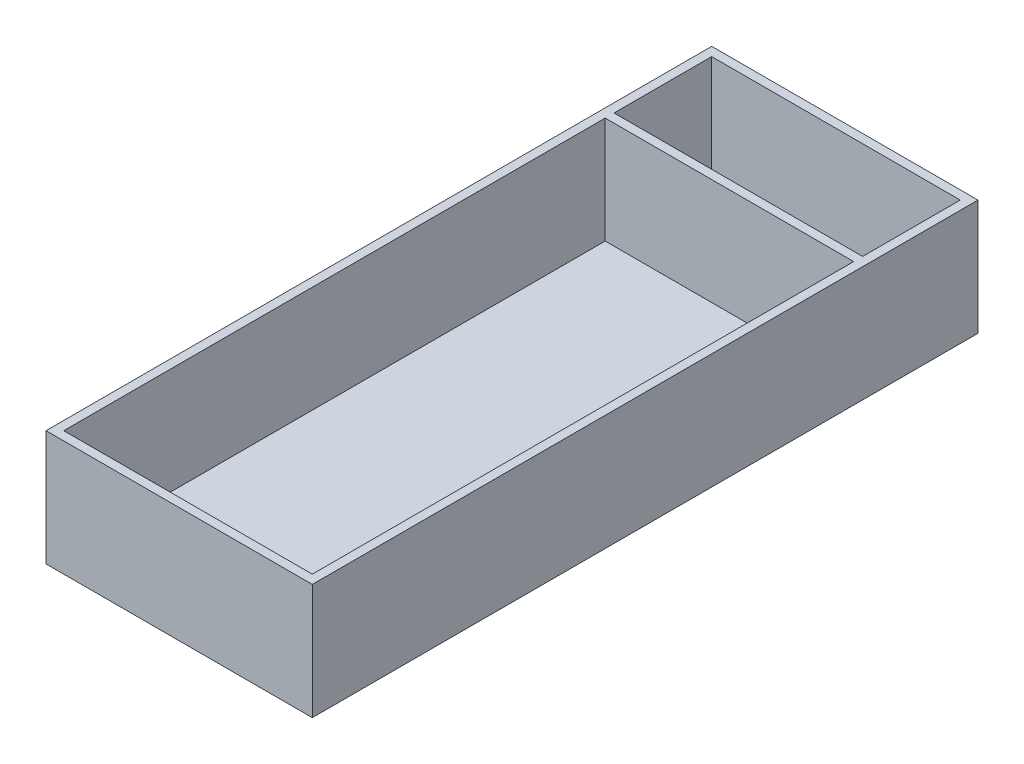
from build123d import *

# Parameters (mm, degrees)
SKETCH1_W           = 76.2
SKETCH1_H           = 190.5
SKETCH1_W_2         = 71.12
SKETCH1_H_2         = 185.42
EXTRUDE_THIN1_DEPTH = 30.48
SKETCH2_W           = 76.2
SKETCH2_H           = 190.5
BOSS_EXTRUDE1_DEPTH = 2.54
SKETCH4_W           = 71.12
SKETCH4_H           = 2.54
BOSS_EXTRUDE2_DEPTH = 30.48


with BuildPart() as part:
    # Sketch1 → Extrude-Thin1 (new body)
    with BuildSketch(Plane(origin=(0, 0, 0), x_dir=(1, 0, 0), z_dir=(0, 1, 0))):
        Rectangle(SKETCH1_W, SKETCH1_H)
        Rectangle(SKETCH1_W_2, SKETCH1_H_2, mode=Mode.SUBTRACT)
    extrude(amount=EXTRUDE_THIN1_DEPTH)

    # Sketch2 → Boss-Extrude1 (add)
    with BuildSketch(Plane.XZ):
        Rectangle(SKETCH2_W, SKETCH2_H)
    extrude(amount=BOSS_EXTRUDE1_DEPTH)

    # Sketch4 → Boss-Extrude2 (add)
    with BuildSketch(Plane(origin=(0, 0, 0), x_dir=(1, 0, 0), z_dir=(0, 1, 0))):
        with Locations((0, 63.5)):
            Rectangle(SKETCH4_W, SKETCH4_H)
    extrude(amount=BOSS_EXTRUDE2_DEPTH)


solid = part.part
